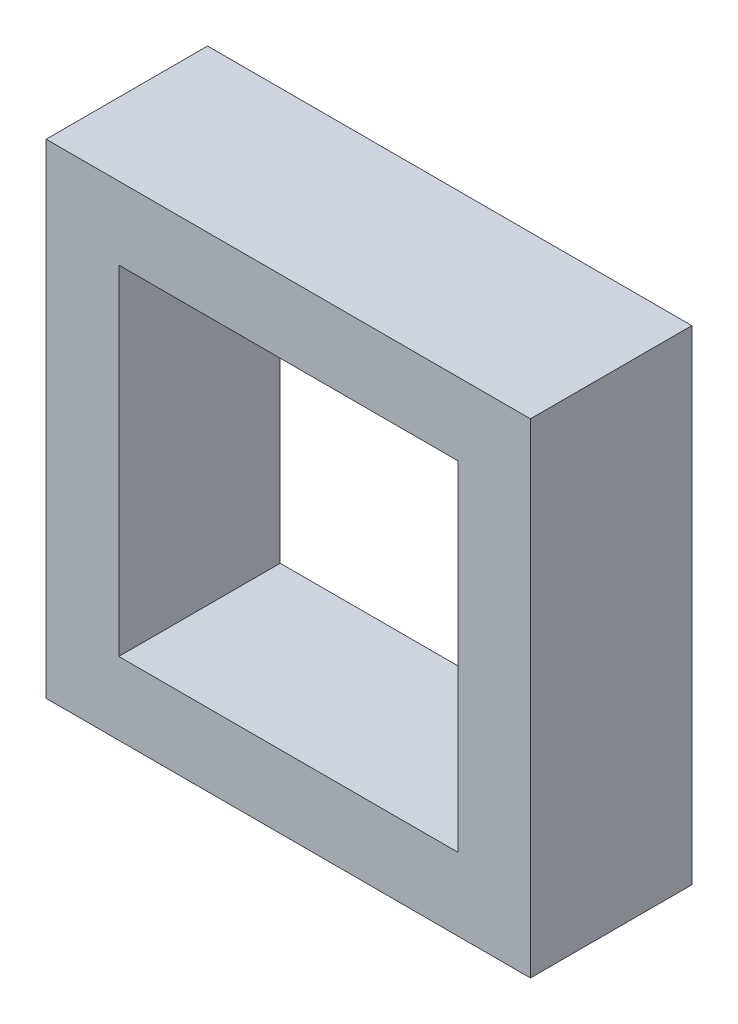
from build123d import *

# Parameters (mm, degrees)
SKETCH1_W           = 6
SKETCH1_H           = 6
SKETCH1_W_2         = 4.2
SKETCH1_H_2         = 4.2
BOSS_EXTRUDE1_DEPTH = 2


with BuildPart() as part:
    # Sketch1 → Boss-Extrude1 (new body)
    with BuildSketch(Plane.XY):
        with Locations((2.1, 2.1)):
            Rectangle(SKETCH1_W, SKETCH1_H)
        with Locations((2.1, 2.1)):
            Rectangle(SKETCH1_W_2, SKETCH1_H_2, mode=Mode.SUBTRACT)
    extrude(amount=BOSS_EXTRUDE1_DEPTH)


solid = part.part
